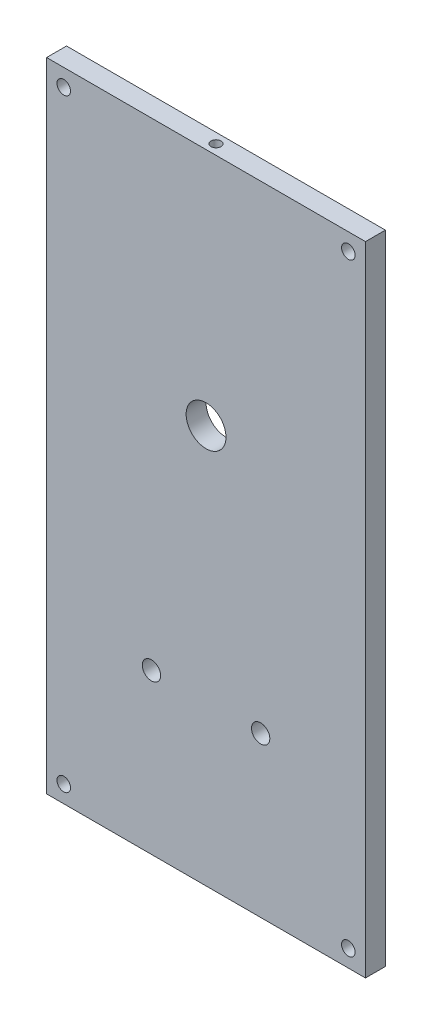
from build123d import *

# Parameters (mm, degrees)
SKETCH1_W           = 50.8
SKETCH1_H           = 101.6
SKETCH1_R           = 1.0795
BOSS_EXTRUDE1_DEPTH = 3.175
SKETCH3_R           = 0.79375
CUT_EXTRUDE1_DEPTH  = 6.35
SKETCH4_R           = 0.79375
CUT_EXTRUDE2_DEPTH  = 3.81
SKETCH5_R           = 3.175
CUT_EXTRUDE3_DEPTH  = 4.175
SKETCH6_R           = 1.4605
CUT_EXTRUDE4_DEPTH  = 4.175


with BuildPart() as part:
    # Sketch1 → Boss-Extrude1 (new body)
    with BuildSketch(Plane.XY):
        with Locations((-30.443913465, -14.686809816)):
            Rectangle(SKETCH1_W, SKETCH1_H)
        with Locations((-53.113413465, 33.382690184)):
            Circle(SKETCH1_R, mode=Mode.SUBTRACT)
        with Locations((-53.113413465, -62.756309816)):
            Circle(SKETCH1_R, mode=Mode.SUBTRACT)
        with Locations((-7.774413465, -62.756309816)):
            Circle(SKETCH1_R, mode=Mode.SUBTRACT)
        with Locations((-7.774413465, 33.382690184)):
            Circle(SKETCH1_R, mode=Mode.SUBTRACT)
    extrude(amount=BOSS_EXTRUDE1_DEPTH)

    # Sketch3 → Cut-Extrude1 (cut)
    with BuildSketch(Plane(origin=(0, 36.113190184, 0), x_dir=(1, 0, 0), z_dir=(0, 1, 0))):
        with Locations(Location((-30.443913465, -1.5875, 0), (0, 0, 270))):  # turned: the seam where the file's is
            Circle(SKETCH3_R)
    extrude(amount=-CUT_EXTRUDE1_DEPTH, mode=Mode.SUBTRACT)

    # Sketch4 → Cut-Extrude2 (cut)
    with BuildSketch(Plane(origin=(0, -65.486809816, 0), x_dir=(-1, 0, 0), z_dir=(0, -1, 0))):
        with Locations(Location((30.443913465, -1.5875, 0), (0, 0, 270))):  # turned: the seam where the file's is
            Circle(SKETCH4_R)
    extrude(amount=-CUT_EXTRUDE2_DEPTH, mode=Mode.SUBTRACT)

    # Sketch5 → Cut-Extrude3 (cut, through all)
    with BuildSketch(Plane.XY.offset(3.175)):
        with Locations((-30.443913465, -1.986809816)):
            Circle(SKETCH5_R)
    extrude(amount=-CUT_EXTRUDE3_DEPTH, mode=Mode.SUBTRACT)

    # Sketch6 → Cut-Extrude4 (cut, through all)
    with BuildSketch(Plane.XY.offset(3.175)):
        with Locations((-39.143413465, -40.086809816)):
            Circle(SKETCH6_R)
        with Locations((-21.744413465, -40.086809816)):
            Circle(SKETCH6_R)
    extrude(amount=-CUT_EXTRUDE4_DEPTH, mode=Mode.SUBTRACT)


solid = part.part
